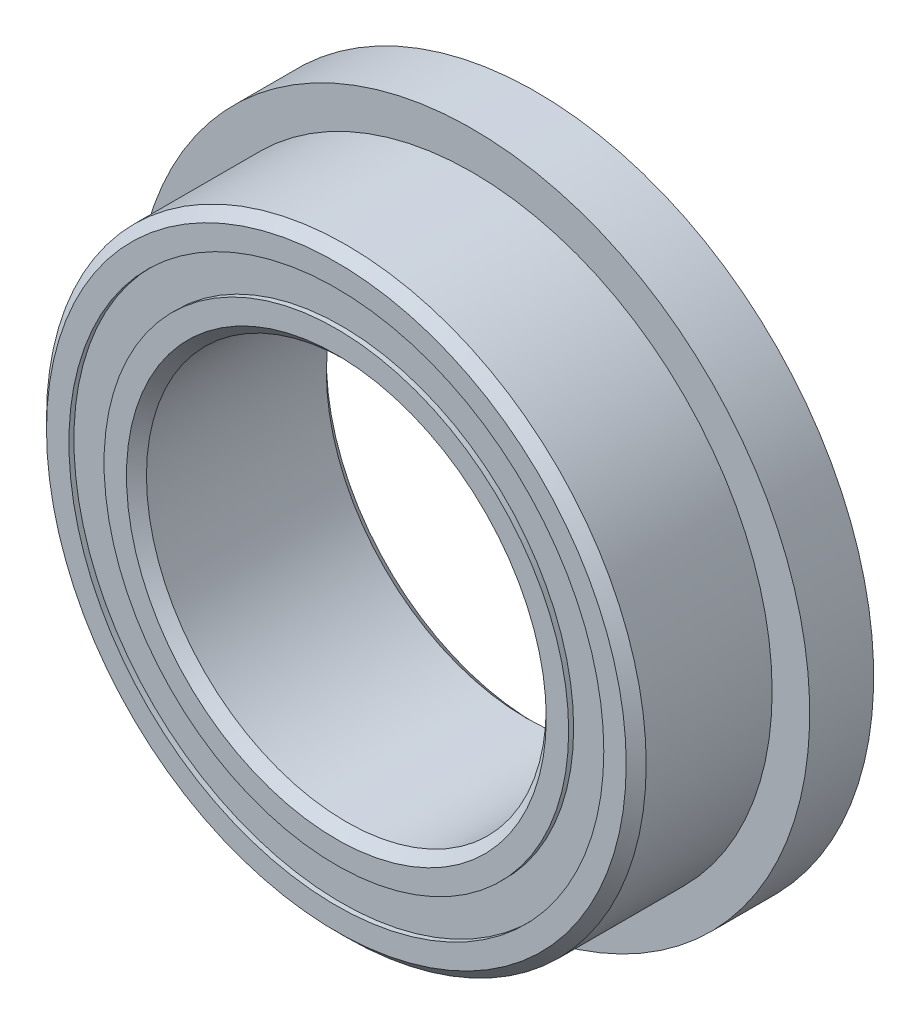
from build123d import *

# Parameters (mm, degrees)
CIRPATTERN1_COUNT = 12
SKETCH5_W         = 0.749364756
SKETCH5_H         = 0.558241758
SKETCH6_W         = 1.016
SKETCH6_H         = 1.111529121


with BuildPart() as part:
    # Sketch1 → Revolve1 (revolve)
    with BuildSketch(Plane(origin=(0, 0, 0), x_dir=(0, 0, -1), z_dir=(1, 0, 0))):
        with BuildLine():
            Line((1.42875, 4.7625), (-1.42875, 4.7625))
            Line((-1.42875, 4.7625), (-1.5875, 4.60375))
            Line((-1.5875, 4.60375), (-1.5875, 4.247870879))
            Line((-1.5875, 4.247870879), (-0.705555556, 4.247870879))
            ThreePointArc((-0.705555556, 4.247870879), (0, 4.727510244), (0.705555556, 4.247870879))
            Line((0.705555556, 4.247870879), (1.5875, 4.247870879))
            Line((1.5875, 4.247870879), (1.5875, 4.60375))
            Line((1.5875, 4.60375), (1.42875, 4.7625))
        make_face()
    revolve(axis=Axis((0, 0, 1.5875), (0, 0, -1)))

    # Sketch6 → Revolve6 (revolve)
    with BuildSketch(Plane(origin=(0, 0, 0), x_dir=(0, 0, -1), z_dir=(1, 0, 0))):
        with Locations((1.0795, 4.80363544)):
            Rectangle(SKETCH6_W, SKETCH6_H)
    revolve(axis=Axis((0, 0, -1.5875), (0, 0, 1)))


with BuildPart() as body_2:
    # Sketch3 → Revolve3 (revolve)
    with BuildSketch(Plane(origin=(0, 0, 0), x_dir=(0, 0, -1), z_dir=(1, 0, 0))):
        with BuildLine():
            Line((-1.5875, 3.689629121), (-0.705555556, 3.689629121))
            ThreePointArc((-0.705555556, 3.689629121), (0, 3.209989756), (0.705555556, 3.689629121))
            Line((0.705555556, 3.689629121), (1.5875, 3.689629121))
            Line((1.5875, 3.689629121), (1.5875, 3.33375))
            Line((1.5875, 3.33375), (1.42875, 3.175))
            Line((1.42875, 3.175), (-1.42875, 3.175))
            Line((-1.42875, 3.175), (-1.5875, 3.33375))
            Line((-1.5875, 3.33375), (-1.5875, 3.689629121))
        make_face()
    revolve(axis=Axis((0, 0, 1.5875), (0, 0, -1)))


with BuildPart() as body_3:
    # Sketch4 → Revolve4 (revolve)
    with BuildSketch(Plane(origin=(0, 0, 0), x_dir=(0, 0, -1), z_dir=(1, 0, 0))):
        with BuildLine():
            Line((-0.758760244, 3.96875), (0.758760244, 3.96875))
            ThreePointArc((0.758760244, 3.96875), (0, 4.727510244), (-0.758760244, 3.96875))
        make_face()
    revolve(axis=Axis((0, 3.96875, 0.758760244), (0, 0, -1)))


with BuildPart() as cirpattern1_1:
    # CirPattern1: pattern copy
    add(body_3.part.rotate(Axis((0, 0, -1.5875), (0, 0, 1)), 1 * 360 / CIRPATTERN1_COUNT))


with BuildPart() as cirpattern1_2:
    # CirPattern1: pattern copy
    add(body_3.part.rotate(Axis((0, 0, -1.5875), (0, 0, 1)), 2 * 360 / CIRPATTERN1_COUNT))


with BuildPart() as cirpattern1_3:
    # CirPattern1: pattern copy
    add(body_3.part.rotate(Axis((0, 0, -1.5875), (0, 0, 1)), 3 * 360 / CIRPATTERN1_COUNT))


with BuildPart() as cirpattern1_4:
    # CirPattern1: pattern copy
    add(body_3.part.rotate(Axis((0, 0, -1.5875), (0, 0, 1)), 4 * 360 / CIRPATTERN1_COUNT))


with BuildPart() as cirpattern1_5:
    # CirPattern1: pattern copy
    add(body_3.part.rotate(Axis((0, 0, -1.5875), (0, 0, 1)), 5 * 360 / CIRPATTERN1_COUNT))


with BuildPart() as cirpattern1_6:
    # CirPattern1: pattern copy
    add(body_3.part.rotate(Axis((0, 0, -1.5875), (0, 0, 1)), 6 * 360 / CIRPATTERN1_COUNT))


with BuildPart() as cirpattern1_7:
    # CirPattern1: pattern copy
    add(body_3.part.rotate(Axis((0, 0, -1.5875), (0, 0, 1)), 7 * 360 / CIRPATTERN1_COUNT))


with BuildPart() as cirpattern1_8:
    # CirPattern1: pattern copy
    add(body_3.part.rotate(Axis((0, 0, -1.5875), (0, 0, 1)), 8 * 360 / CIRPATTERN1_COUNT))


with BuildPart() as cirpattern1_9:
    # CirPattern1: pattern copy
    add(body_3.part.rotate(Axis((0, 0, -1.5875), (0, 0, 1)), 9 * 360 / CIRPATTERN1_COUNT))


with BuildPart() as cirpattern1_10:
    # CirPattern1: pattern copy
    add(body_3.part.rotate(Axis((0, 0, -1.5875), (0, 0, 1)), 10 * 360 / CIRPATTERN1_COUNT))


with BuildPart() as cirpattern1_11:
    # CirPattern1: pattern copy
    add(body_3.part.rotate(Axis((0, 0, -1.5875), (0, 0, 1)), 11 * 360 / CIRPATTERN1_COUNT))


with BuildPart() as body_15:
    # Sketch5 → Revolve5 (revolve)
    with BuildSketch(Plane(origin=(0, 0, 0), x_dir=(0, 0, -1), z_dir=(1, 0, 0))):
        with Locations((-1.133442622, 3.96875)):
            Rectangle(SKETCH5_W, SKETCH5_H)
        with Locations((1.133442622, 3.96875)):
            Rectangle(SKETCH5_W, SKETCH5_H)
    revolve(axis=Axis((0, 0, 1.5875), (0, 0, -1)))


solid = Compound([part.part, body_2.part, body_3.part, cirpattern1_1.part, cirpattern1_2.part, cirpattern1_3.part, cirpattern1_4.part, cirpattern1_5.part, cirpattern1_6.part, cirpattern1_7.part, cirpattern1_8.part, cirpattern1_9.part, cirpattern1_10.part, cirpattern1_11.part, body_15.part])
